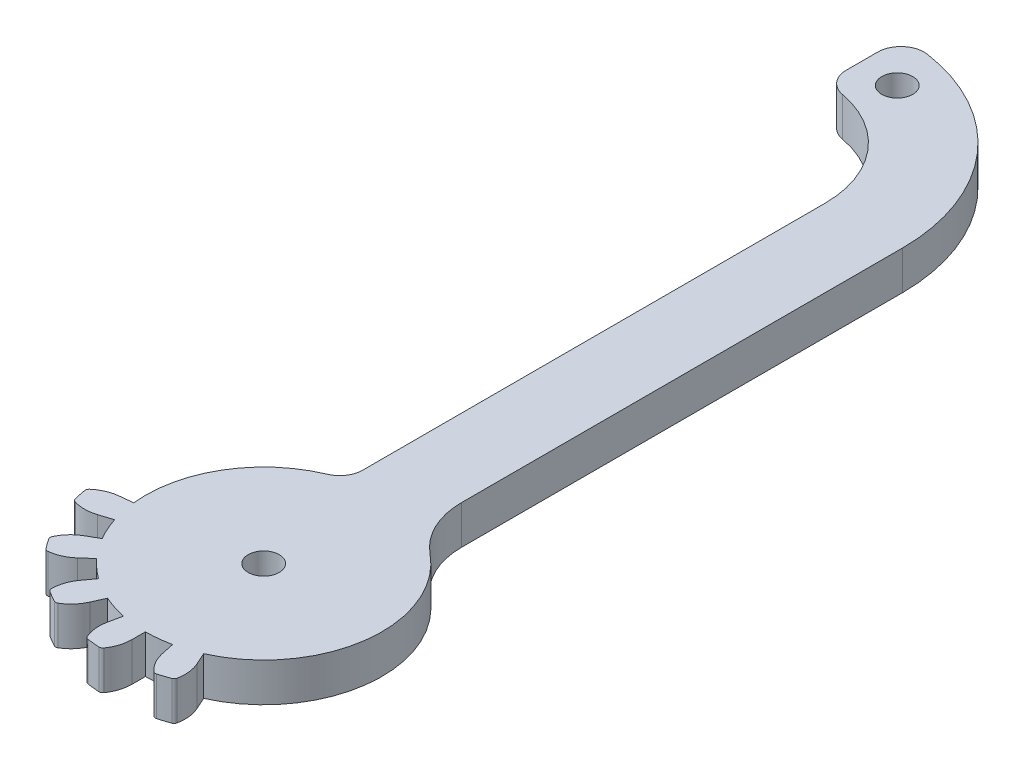
from build123d import *

# Parameters (mm, degrees)
SKETCH1_R           = 2
BOSS_EXTRUDE3_DEPTH = 5
FILLET9_R           = 10
FILLET10_R          = 3
FILLET11_R          = 3
FILLET12_R          = 3
FILLET13_R          = 0.5


with BuildPart() as part:
    # Sketch1 → Boss-Extrude3 (new body)
    with BuildSketch(Plane(origin=(0, 0, 0), x_dir=(1, 0, 0), z_dir=(0, 1, 0))):
        with BuildLine():
            Line((-4.046119318, 54.590604732), (-4.046119318, -7.195574606))
            ThreePointArc((-4.046119318, -7.195574606), (-11.635335702, -12.035866866), (-15.176119318, -20.311583503))
            ThreePointArc((-15.176119318, -20.311583503), (-15.239015435, -21.109389908), (-15.26, -21.909396551))
            ThreePointArc((-15.26, -21.909396551), (-15.239086668, -22.708042569), (-15.17640413, -23.504499555))
            Line((-15.17640413, -23.504499555), (-16.906872391, -23.686379161))
            ThreePointArc((-16.906872391, -23.686379161), (-18.44583537, -24.118938522), (-19.753766933, -25.038084689))
            ThreePointArc((-19.753766933, -25.038084689), (-19.56295199, -26.067629867), (-19.318516287, -27.085777598))
            ThreePointArc((-19.318516287, -27.085777598), (-17.749810888, -27.393475541), (-16.167960532, -27.162685373))
            Line((-16.167960532, -27.162685373), (-14.513122101, -26.624995641))
            ThreePointArc((-14.513122101, -26.624995641), (-14.246436916, -27.378091201), (-13.940703236, -28.116197446))
            ThreePointArc((-13.940703236, -28.116197446), (-13.596759365, -28.837290674), (-13.215547785, -29.539395055))
            Line((-13.215547785, -29.539395055), (-14.722432114, -30.409395176))
            ThreePointArc((-14.722432114, -30.409395176), (-15.952407023, -31.430510437), (-16.773411552, -32.802175926))
            ThreePointArc((-16.773411552, -32.802175926), (-16.180339688, -33.665100824), (-15.542918581, -34.49580411))
            ThreePointArc((-15.542918581, -34.49580411), (-13.984682857, -34.138850219), (-12.633461458, -33.284616422))
            Line((-12.633461458, -33.284616422), (-11.340389428, -32.120328997))
            ThreePointArc((-11.340389428, -32.120328997), (-10.790448835, -32.699845394), (-10.210932372, -33.249785918))
            ThreePointArc((-10.210932372, -33.249785918), (-9.603428978, -33.768642793), (-8.969603297, -34.25499435))
            Line((-8.969603297, -34.25499435), (-9.99234972, -35.66268407))
            ThreePointArc((-9.99234972, -35.66268407), (-10.700662735, -37.095795135), (-10.892781095, -38.682806536))
            ThreePointArc((-10.892781095, -38.682806536), (-9.999999818, -39.229903609), (-9.079809202, -39.729526311))
            ThreePointArc((-9.079809202, -39.729526311), (-7.80147625, -38.769641154), (-6.914522249, -37.439668504))
            Line((-6.914522249, -37.439668504), (-6.20680051, -35.850099247))
            ThreePointArc((-6.20680051, -35.850099247), (-5.468694229, -36.155832838), (-4.715598637, -36.422517933))
            ThreePointArc((-4.715598637, -36.422517933), (-3.94957857, -36.649423393), (-3.172733001, -36.835927528))
            Line((-3.172733001, -36.835927528), (-3.534499379, -38.53790452))
            ThreePointArc((-3.534499379, -38.53790452), (-3.598676752, -40.135213481), (-3.128689936, -41.66316212))
            ThreePointArc((-3.128689936, -41.66316212), (-2.09056923, -41.799833318), (-1.046718412, -41.881986139))
            ThreePointArc((-1.046718412, -41.881986139), (-0.269323601, -40.48514257), (6.05e-07, -38.909395406))
            Line((6.05e-07, -38.909395406), (5.43e-07, -37.169395268))
            ThreePointArc((5.43e-07, -37.169395268), (0.798647238, -37.14848194), (1.595104896, -37.085799334))
            ThreePointArc((1.595104896, -37.085799334), (2.387189815, -36.981519365), (3.172731623, -36.835927821))
            Line((3.172731623, -36.835927821), (3.534497981, -38.537904817))
            ThreePointArc((3.534497981, -38.537904817), (4.1255531, -40.023222459), (5.176380106, -41.22791215))
            ThreePointArc((5.176380106, -41.22791215), (6.180339749, -40.930525784), (7.167359489, -40.581003755))
            ThreePointArc((7.167359489, -40.581003755), (7.309397542, -38.988728703), (6.914523355, -37.439668011))
            Line((6.914523355, -37.439668011), (6.206801502, -35.850098805))
            ThreePointArc((6.206801502, -35.850098805), (6.927895349, -35.506154662), (7.630000317, -35.124942746))
            ThreePointArc((7.630000317, -35.124942746), (8.311191417, -34.707508302), (8.969602158, -34.254995178))
            ThreePointArc((8.969602158, -34.254995178), (10.210932755, -33.249785573), (11.340390155, -32.12032819))
            ThreePointArc((11.340390155, -32.12032819), (11.859247485, -31.512824296), (12.345599442, -30.87899807))
            ThreePointArc((12.345599442, -30.87899807), (12.7981126, -30.220587353), (13.215547081, -29.539396275))
            ThreePointArc((13.215547081, -29.539396275), (13.940703446, -28.116196975), (14.513122436, -26.624994609))
            ThreePointArc((14.513122436, -26.624994609), (14.740028108, -25.8589739), (14.926532387, -25.08212767))
            ThreePointArc((14.926532387, -25.08212767), (13.533608818, -14.858931995), (5.953880682, -7.858811478))
            Line((5.953880682, -7.858811478), (5.953880682, 54.590604732))
            ThreePointArc((5.953880682, 54.590604732), (-0.92910996, 71.20761409), (-17.546119318, 78.090604732))
            Line((-17.546119318, 78.090604732), (-17.546119318, 68.090604732))
            ThreePointArc((-17.546119318, 68.090604732), (-8.000177772, 64.136546278), (-4.046119318, 54.590604732))
        make_face()
        with Locations((0, -21.909395268)):
            Circle(SKETCH1_R, mode=Mode.SUBTRACT)
        with Locations((-12.546119318, 72.402117863)):
            Circle(SKETCH1_R, mode=Mode.SUBTRACT)
    extrude(amount=BOSS_EXTRUDE3_DEPTH)

    # Fillet9
    fillet9_edges = [part.edges().sort_by_distance(p)[0] for p in [
        (5.953880682, 2.5, 7.858811478),
    ]]
    fillet(fillet9_edges, radius=FILLET9_R)

    # Fillet10
    fillet10_edges = [part.edges().sort_by_distance(p)[0] for p in [
        (-4.046119318, 2.5, 7.195574606),
    ]]
    fillet(fillet10_edges, radius=FILLET10_R)

    # Fillet11
    fillet11_edges = [part.edges().sort_by_distance(p)[0] for p in [
        (-17.546119318, 2.5, -78.090604732),
    ]]
    fillet(fillet11_edges, radius=FILLET11_R)

    # Fillet12
    fillet12_edges = [part.edges().sort_by_distance(p)[0] for p in [
        (-17.546119318, 2.5, -68.090604732),
    ]]
    fillet(fillet12_edges, radius=FILLET12_R)

    # Fillet13
    fillet13_edges = [part.edges().sort_by_distance(p)[0] for p in [
        (7.167359489, 2.5, 40.581003755),
        (5.176380106, 2.5, 41.22791215),
        (-1.046718412, 2.5, 41.881986139),
        (-3.128689936, 2.5, 41.66316212),
        (-9.079809202, 2.5, 39.729526311),
        (-10.892781095, 2.5, 38.682806536),
        (-15.542918581, 2.5, 34.49580411),
        (-16.773411552, 2.5, 32.802175926),
        (-19.318516287, 2.5, 27.085777598),
        (-19.753766933, 2.5, 25.038084689),
    ]]
    fillet(fillet13_edges, radius=FILLET13_R)


solid = part.part
